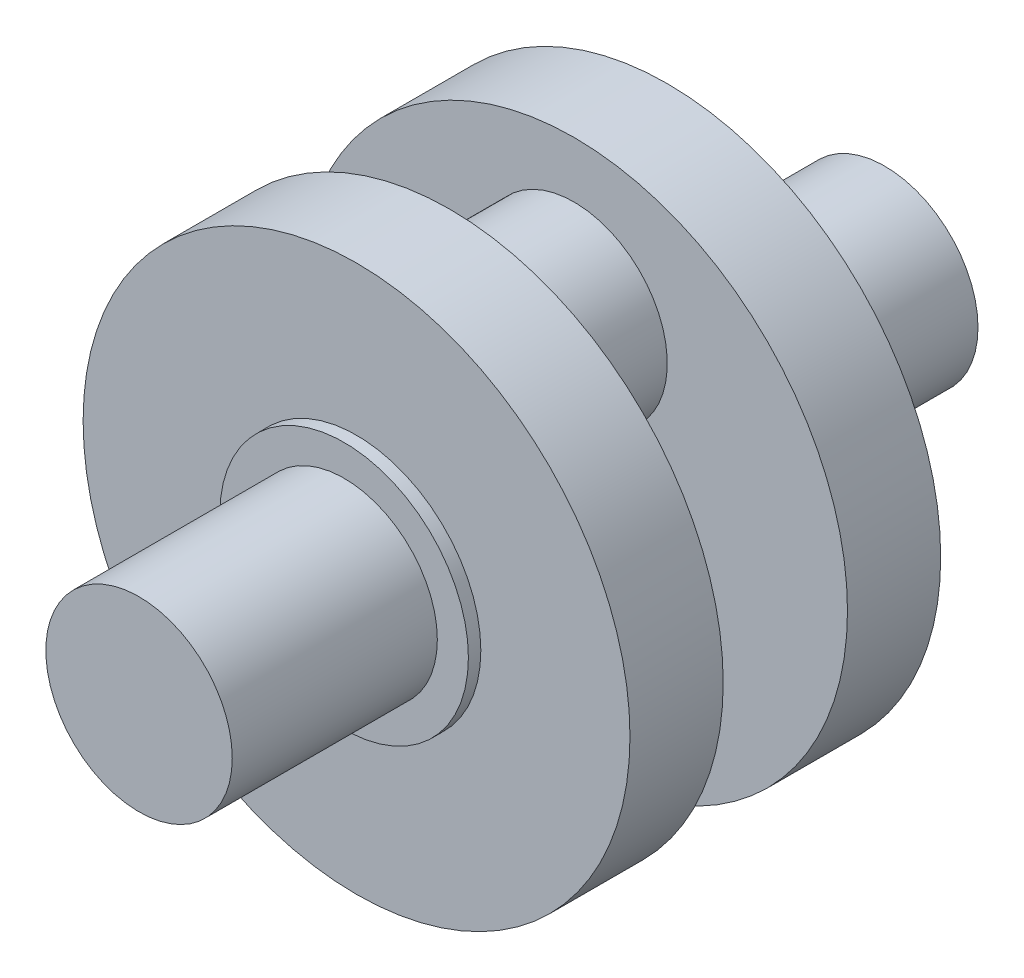
from build123d import *

# Parameters (mm, degrees)
SZKIC1_R                    = 15
DODANIE_WYCI_GNI_CIE1_DEPTH = 33
SZKIC2_R                    = 20
DODANIE_WYCI_GNI_CIE2_DEPTH = 2
SZKIC3_R                    = 44
DODANIE_WYCI_GNI_CIE3_DEPTH = 15
SZKIC4_R                    = 15
DODANIE_WYCI_GNI_CIE4_DEPTH = 10


with BuildPart() as part:
    # Szkic1 → Dodanie-wyciągnięcie1 (new body)
    with BuildSketch(Plane.XY):
        Circle(SZKIC1_R)
    extrude(amount=DODANIE_WYCI_GNI_CIE1_DEPTH)

    # Szkic2 → Dodanie-wyciągnięcie2 (add)
    with BuildSketch(Plane.XY):
        Circle(SZKIC2_R)
    extrude(amount=-DODANIE_WYCI_GNI_CIE2_DEPTH)

    # Szkic3 → Dodanie-wyciągnięcie3 (add)
    with BuildSketch(Plane(origin=(0, 0, -2), x_dir=(-1, 0, 0), z_dir=(0, 0, -1))):
        Circle(SZKIC3_R)
    extrude(amount=DODANIE_WYCI_GNI_CIE3_DEPTH)

    # Szkic4 → Dodanie-wyciągnięcie4 (add)
    with BuildSketch(Plane(origin=(0, 0, -17), x_dir=(-1, 0, 0), z_dir=(0, 0, -1))):
        with Locations((0, 20)):
            Circle(SZKIC4_R)
    extrude(amount=DODANIE_WYCI_GNI_CIE4_DEPTH)

    # Lustro2: part across plane


with BuildPart() as part_1:
    add(part.part)
    add(part.part.mirror(Plane(origin=(0, 20, -27), x_dir=(1, 0, 0), z_dir=(0, 0, -1))))


solid = part_1.part
